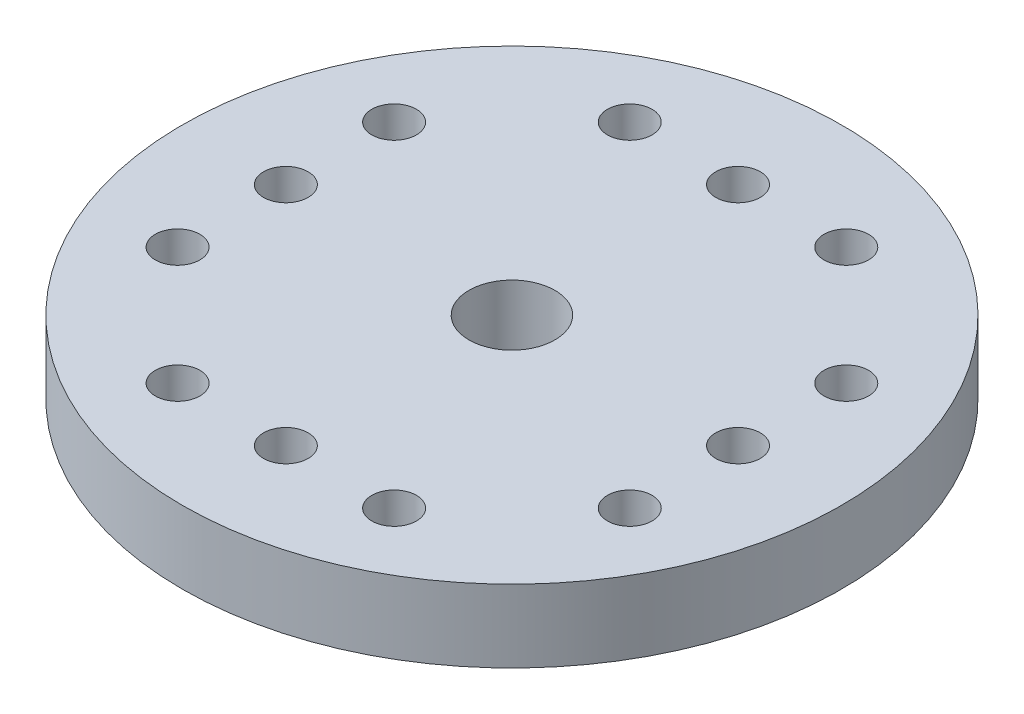
from build123d import *

# Parameters (mm, degrees)
SKETCH1_R           = 10.35
BOSS_EXTRUDE1_DEPTH = 2.28
SKETCH2_R           = 4.35
BOSS_EXTRUDE2_DEPTH = 3.1
SKETCH3_R           = 1.35
CUT_EXTRUDE1_DEPTH  = 6.38
SKETCH4_R           = 2.65
CUT_EXTRUDE2_DEPTH  = 3.1
SKETCH5_R           = 0.7
CUT_EXTRUDE3_DEPTH  = 3.1
CIRPATTERN1_COUNT   = 4


with BuildPart() as part:
    # Sketch1 → Boss-Extrude1 (new body)
    with BuildSketch(Plane(origin=(0, 0, 0), x_dir=(1, 0, 0), z_dir=(0, 1, 0))):
        Circle(SKETCH1_R)
    extrude(amount=-BOSS_EXTRUDE1_DEPTH)

    # Sketch2 → Boss-Extrude2 (add)
    with BuildSketch(Plane.XZ.offset(2.28)):
        Circle(SKETCH2_R)
    extrude(amount=BOSS_EXTRUDE2_DEPTH)

    # Sketch3 → Cut-Extrude1 (cut, through all)
    with BuildSketch(Plane(origin=(0, 0, 0), x_dir=(1, 0, 0), z_dir=(0, 1, 0))):
        Circle(SKETCH3_R)
    extrude(amount=-CUT_EXTRUDE1_DEPTH, mode=Mode.SUBTRACT)

    # Sketch4 → Cut-Extrude2 (cut)
    with BuildSketch(Plane.XZ.offset(5.38)):
        Circle(SKETCH4_R)
    extrude(amount=-CUT_EXTRUDE2_DEPTH, mode=Mode.SUBTRACT)

    # Sketch5 → Cut-Extrude3 (cut)
    with BuildSketch(Plane(origin=(0, 0, 0), x_dir=(1, 0, 0), z_dir=(0, 1, 0))):
        with Locations((7.1, 3.4)):
            Circle(SKETCH5_R)
        with Locations((7.1, 0)):
            Circle(SKETCH5_R)
        with Locations((7.1, -3.4)):
            Circle(SKETCH5_R)
    cut_extrude3 = extrude(amount=-CUT_EXTRUDE3_DEPTH, mode=Mode.SUBTRACT)

    # CirPattern1: Cut-Extrude3 ×4 about axis
    cirpattern1_axis = Axis((0, 0, 0), (0, 1, 0))
    for i in range(1, CIRPATTERN1_COUNT):
        add(cut_extrude3.rotate(cirpattern1_axis, i * 360 / CIRPATTERN1_COUNT), mode=Mode.SUBTRACT)


solid = part.part
